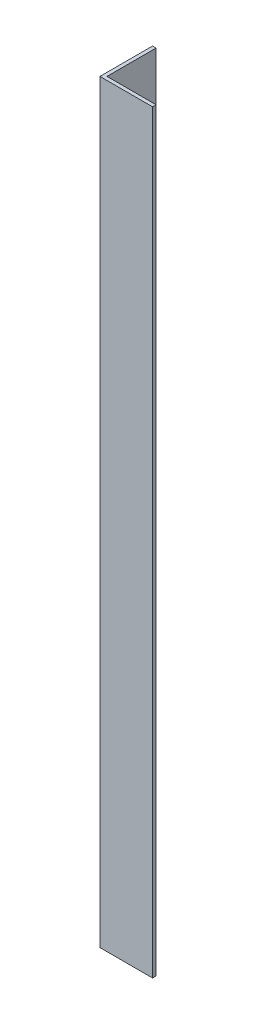
from build123d import *

# Parameters (mm, degrees)
EXTRUDE_1_DEPTH = 215


with BuildPart() as part:
    # Эскиз1 → Бобышка-Вытянуть1 (new body)
    with BuildSketch(Plane(origin=(0, 0, 0), x_dir=(1, 0, 0), z_dir=(0, 1, 0))):
        Polygon((0, 0), (0, 15), (1, 15), (1, 1), (15, 1), (15, 0), align=None)
    extrude(amount=EXTRUDE_1_DEPTH)


solid = part.part
